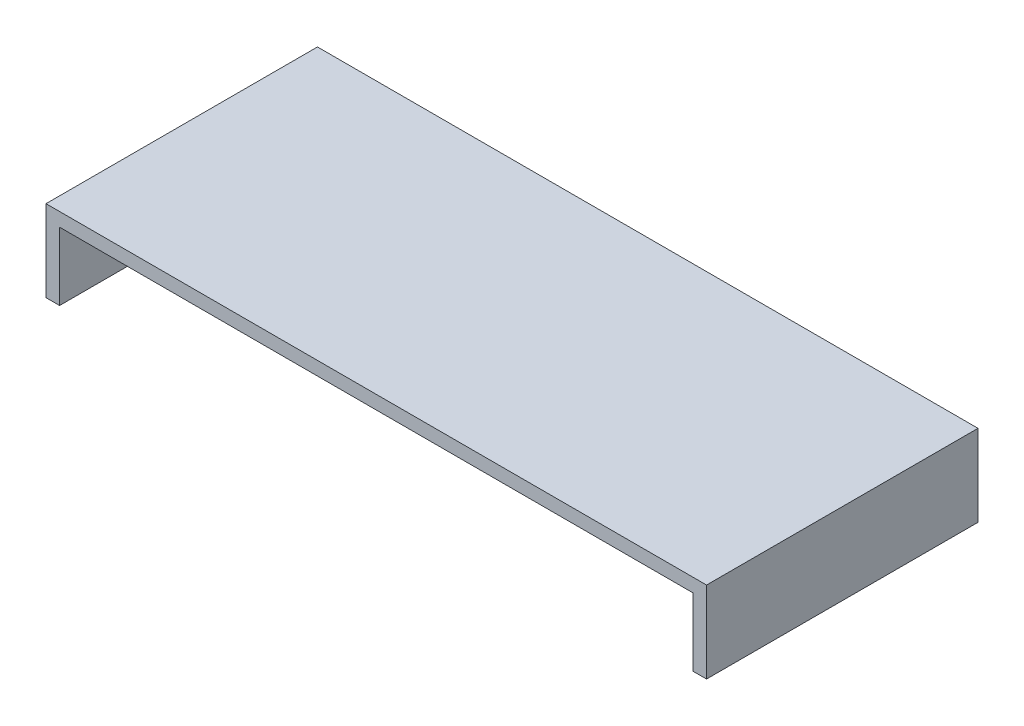
from build123d import *

# Parameters (mm, degrees)
SKETCH1_W           = 0.146
SKETCH1_H           = 0.06
BOSS_EXTRUDE1_DEPTH = 0.018
SKETCH4_W           = 0.14
SKETCH4_H           = 0.06
CUT_EXTRUDE1_DEPTH  = 0.015


with BuildPart() as part:
    # Sketch1 → Boss-Extrude1 (new body)
    with BuildSketch(Plane(origin=(0, 0, 0), x_dir=(1, 0, 0), z_dir=(0, 1, 0))):
        with Locations((0.073, 0.03)):
            Rectangle(SKETCH1_W, SKETCH1_H)
    extrude(amount=BOSS_EXTRUDE1_DEPTH)

    # Sketch4 → Cut-Extrude1 (cut)
    with BuildSketch(Plane.XZ):
        with Locations((0.073, -0.03)):
            Rectangle(SKETCH4_W, SKETCH4_H)
    extrude(amount=-CUT_EXTRUDE1_DEPTH, mode=Mode.SUBTRACT)


solid = part.part
